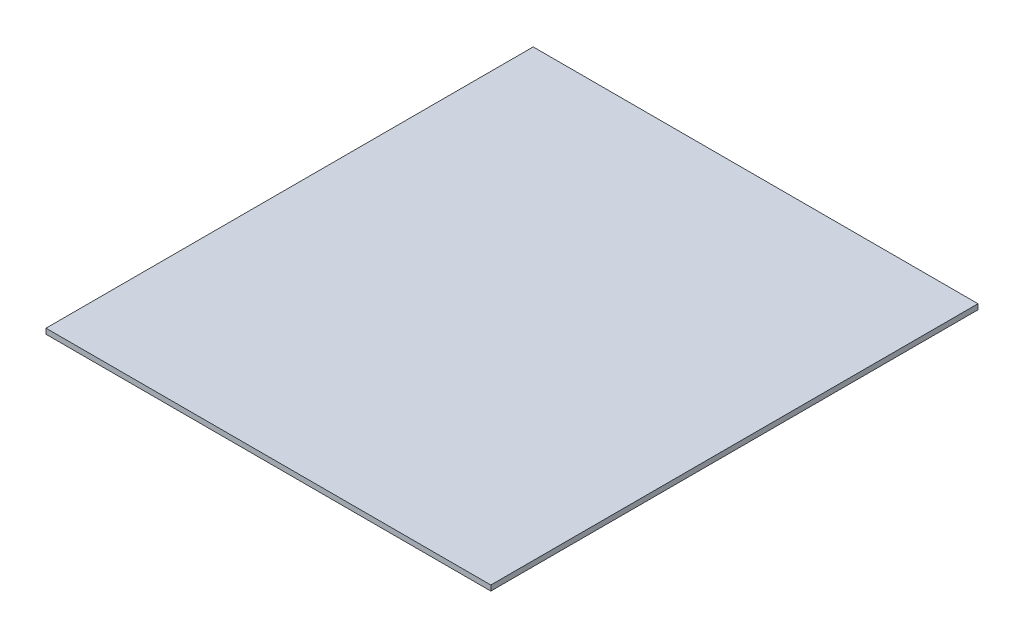
from build123d import *

# Parameters (mm, degrees)
SKETCH1_W           = 133.35
SKETCH1_H           = 146.05
BOSS_EXTRUDE1_DEPTH = 1.5875


with BuildPart() as part:
    # Sketch1 → Boss-Extrude1 (new body)
    with BuildSketch(Plane(origin=(0, 0, 0), x_dir=(1, 0, 0), z_dir=(0, 1, 0))):
        with Locations((66.675, 73.025)):
            Rectangle(SKETCH1_W, SKETCH1_H)
    extrude(amount=BOSS_EXTRUDE1_DEPTH)


solid = part.part
